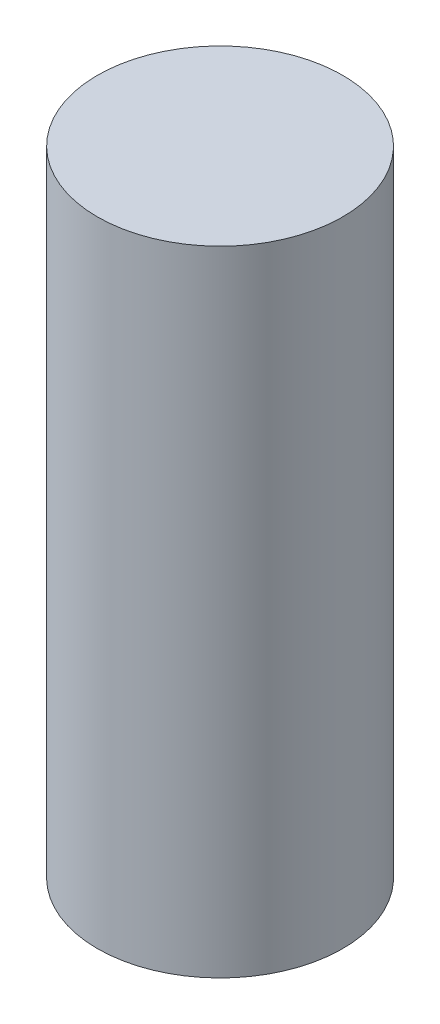
from build123d import *

# Parameters (mm, degrees)
SKETCH1_R           = 6
BOSS_EXTRUDE1_DEPTH = 31


with BuildPart() as part:
    # Sketch1 → Boss-Extrude1 (new body)
    with BuildSketch(Plane(origin=(0, 0, 0), x_dir=(1, 0, 0), z_dir=(0, 1, 0))):
        Circle(SKETCH1_R)
    extrude(amount=BOSS_EXTRUDE1_DEPTH)


solid = part.part
